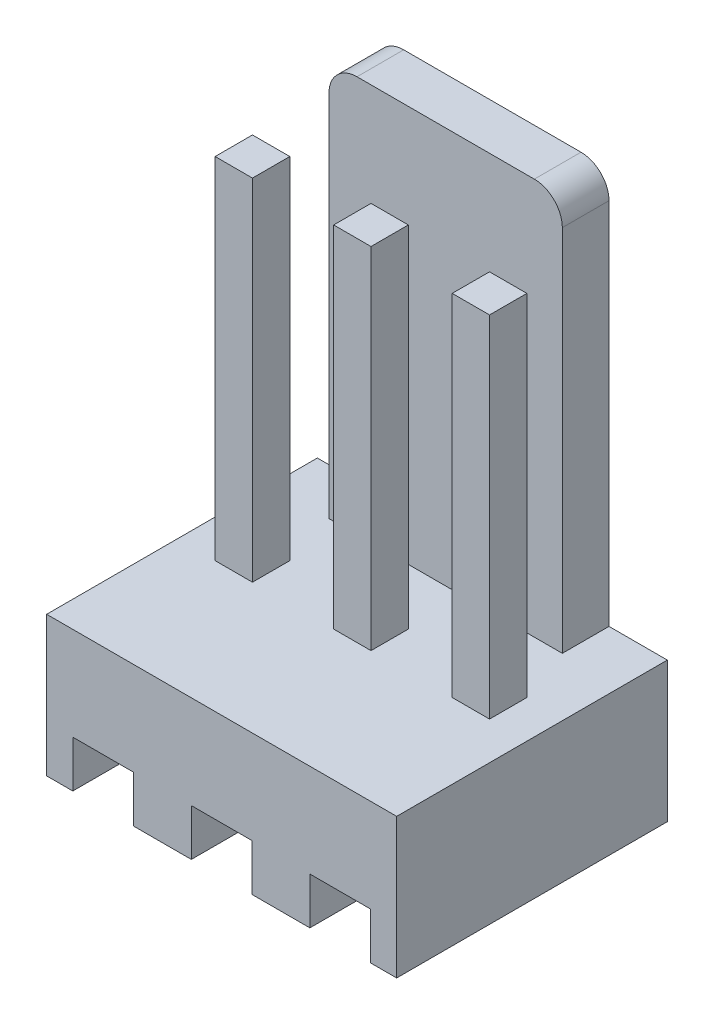
from build123d import *

# Parameters (mm, degrees)
CROQUIS1_W            = 7.5
CROQUIS1_H            = 5.8
EXTRUIR1_DEPTH        = 11.5
CROQUIS2_W            = 6.137919575
CROQUIS2_H            = 10.958568738
CORTAR_EXTRUIR1_DEPTH = 11.5
CROQUIS3_W            = 2.217883387
CROQUIS3_H            = 8.857556959
CROQUIS3_W_2          = 2.732635427
CORTAR_EXTRUIR2_DEPTH = 11.5
REDONDEO1_R           = 0.6
CROQUIS4_W            = 0.8
CROQUIS4_H            = 0.8
EXTRUIR2_DEPTH        = 7.5
EXTRUIR2_2_DEPTH      = 7.5
EXTRUIR2_3_DEPTH      = 7.5
CROQUIS5_W            = 1.3
CROQUIS5_H            = 1.427624534
CORTAR_EXTRUIR3_DEPTH = 7.5


with BuildPart() as part:
    # Croquis1 → Extruir1 (new body)
    with BuildSketch(Plane(origin=(0, 0, 0), x_dir=(1, 0, 0), z_dir=(0, 1, 0))):
        with Locations((3.75, 2.9)):
            Rectangle(CROQUIS1_W, CROQUIS1_H)
    extrude(amount=EXTRUIR1_DEPTH)

    # Croquis2 → Cortar-Extruir1 (cut)
    with BuildSketch(Plane(origin=(7.5, 0, 0), x_dir=(0, 0, -1), z_dir=(1, 0, 0))):
        with Locations((1.731040213, 8.479284369)):
            Rectangle(CROQUIS2_W, CROQUIS2_H)
    extrude(amount=-CORTAR_EXTRUIR1_DEPTH, mode=Mode.SUBTRACT)

    # Croquis3 → Cortar-Extruir2 (cut)
    with BuildSketch(Plane.XY.offset(-4.8)):
        with Locations((0.141058306, 7.42877848)):
            Rectangle(CROQUIS3_W, CROQUIS3_H)
        with Locations((7.616317713, 7.42877848)):
            Rectangle(CROQUIS3_W_2, CROQUIS3_H)
    extrude(amount=-CORTAR_EXTRUIR2_DEPTH, mode=Mode.SUBTRACT)

    # Redondeo1
    redondeo1_edges = [part.edges().sort_by_distance(p)[0] for p in [
        (1.25, 11.5, -5.3),
        (6.25, 11.5, -5.3),
    ]]
    fillet(redondeo1_edges, radius=REDONDEO1_R)

    # Croquis5 → Cortar-Extruir3 (cut)
    with BuildSketch(Plane.XY):
        with Locations((3.75, 0.286187733)):
            Rectangle(CROQUIS5_W, CROQUIS5_H)
        with Locations((6.29, 0.286187733)):
            Rectangle(CROQUIS5_W, CROQUIS5_H)
        with Locations((1.21, 0.286187733)):
            Rectangle(CROQUIS5_W, CROQUIS5_H)
    extrude(amount=-CORTAR_EXTRUIR3_DEPTH, mode=Mode.SUBTRACT)


with BuildPart() as body_2:
    # Croquis4 → Extruir2 (new body)
    with BuildSketch(Plane(origin=(0, 3, 0), x_dir=(1, 0, 0), z_dir=(0, 1, 0))):
        with Locations((3.75, 3.2)):
            Rectangle(CROQUIS4_W, CROQUIS4_H)
    extrude(amount=EXTRUIR2_DEPTH)


with BuildPart() as body_3:
    # Croquis4 → Extruir2 2 (new body)
    with BuildSketch(Plane(origin=(0, 3, 0), x_dir=(1, 0, 0), z_dir=(0, 1, 0))):
        with Locations((6.29, 3.2)):
            Rectangle(CROQUIS4_W, CROQUIS4_H)
    extrude(amount=EXTRUIR2_2_DEPTH)


with BuildPart() as body_4:
    # Croquis4 → Extruir2 3 (new body)
    with BuildSketch(Plane(origin=(0, 3, 0), x_dir=(1, 0, 0), z_dir=(0, 1, 0))):
        with Locations((1.21, 3.2)):
            Rectangle(CROQUIS4_W, CROQUIS4_H)
    extrude(amount=EXTRUIR2_3_DEPTH)


solid = Compound([part.part, body_2.part, body_3.part, body_4.part])
